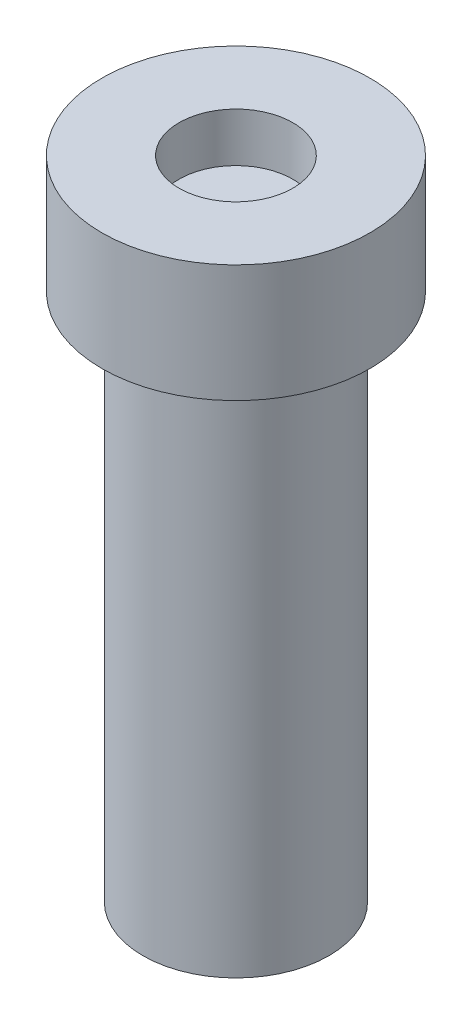
from build123d import *


with BuildPart() as part:
    # Sketch1 → Revolve1 (revolve)
    with BuildSketch(Plane.XY):
        Polygon((2.902359124, 31.060209374), (6.842054747, 31.060209374), (6.842054747, 25.060209374), (4.75, 25.060209374), (4.75, -1.939790626), (0, -1.939790626), (0, 28.560209374), (2.902359124, 28.560209374), align=None)
    revolve(axis=Axis((0, 0, 0), (0, -1, 0)))


solid = part.part
